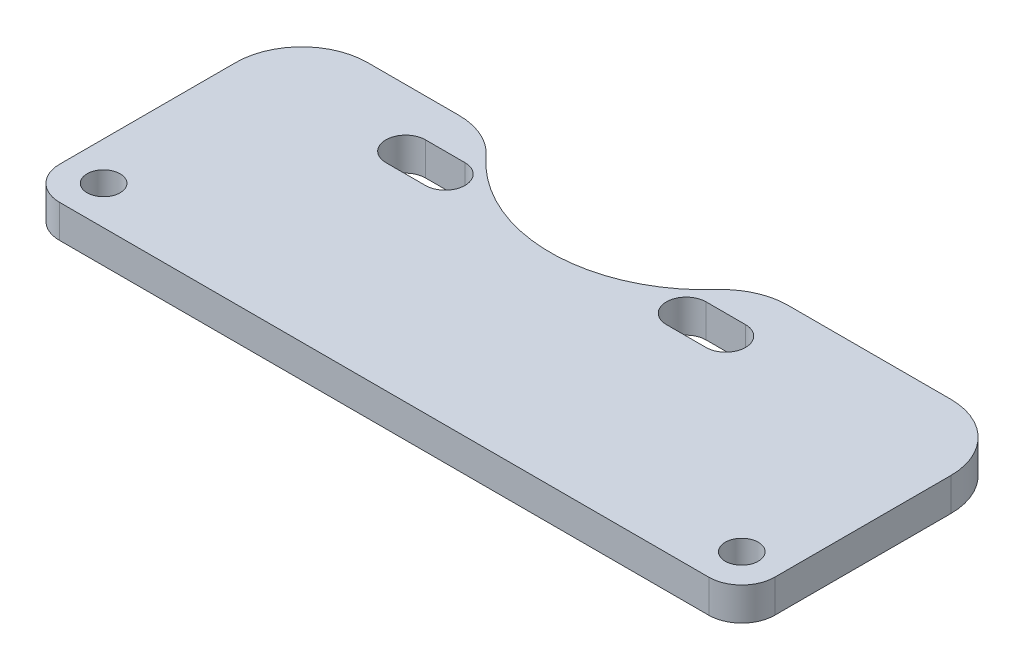
from build123d import *

# Parameters (mm, degrees)
SKETCH1_R           = 1.5
BOSS_EXTRUDE1_DEPTH = 3
FILLET1_R           = 3
FILLET2_R           = 6


with BuildPart() as part:
    # Sketch1 → Boss-Extrude1 (new body)
    with BuildSketch(Plane(origin=(0, 0, 0), x_dir=(1, 0, 0), z_dir=(0, 1, 0))):
        with BuildLine():
            Line((-42.5, -3), (-42.5, -28))
            Line((-42.5, -28), (22.5, -28))
            Line((22.5, -28), (22.5, -3))
            Line((22.5, -3), (-1.251145888, -3))
            ThreePointArc((-1.251145888, -3), (-13.25, -9.65), (-25.248854112, -3))
            Line((-25.248854112, -3), (-42.5, -3))
        make_face()
        with Locations((-39, -24.5)):
            Circle(SKETCH1_R, mode=Mode.SUBTRACT)
        with BuildLine():
            ThreePointArc((-24.202730122, -6.452730122), (-22.405460244, -8.25), (-24.202730122, -10.047269878))
            Line((-24.202730122, -10.047269878), (-27.797269878, -10.047269878))
            ThreePointArc((-27.797269878, -10.047269878), (-29.594539756, -8.25), (-27.797269878, -6.452730122))
            Line((-27.797269878, -6.452730122), (-24.202730122, -6.452730122))
        make_face(mode=Mode.SUBTRACT)
        with Locations((19, -24.5)):
            Circle(SKETCH1_R, mode=Mode.SUBTRACT)
        with BuildLine():
            ThreePointArc((-2.297269878, -10.047269878), (-4.094539756, -8.25), (-2.297269878, -6.452730122))
            Line((-2.297269878, -6.452730122), (1.297269878, -6.452730122))
            ThreePointArc((1.297269878, -6.452730122), (3.094539756, -8.25), (1.297269878, -10.047269878))
            Line((1.297269878, -10.047269878), (-2.297269878, -10.047269878))
        make_face(mode=Mode.SUBTRACT)
    extrude(amount=BOSS_EXTRUDE1_DEPTH)

    # Fillet1
    fillet1_edges = [part.edges().sort_by_distance(p)[0] for p in [
        (22.5, 1.5, 28),
        (-42.5, 1.5, 28),
    ]]
    fillet(fillet1_edges, radius=FILLET1_R)

    # Fillet2
    fillet2_edges = [part.edges().sort_by_distance(p)[0] for p in [
        (-1.251145888, 1.5, 3),
        (22.5, 1.5, 3),
        (-42.5, 1.5, 3),
        (-25.248854112, 1.5, 3),
    ]]
    fillet(fillet2_edges, radius=FILLET2_R)


solid = part.part
